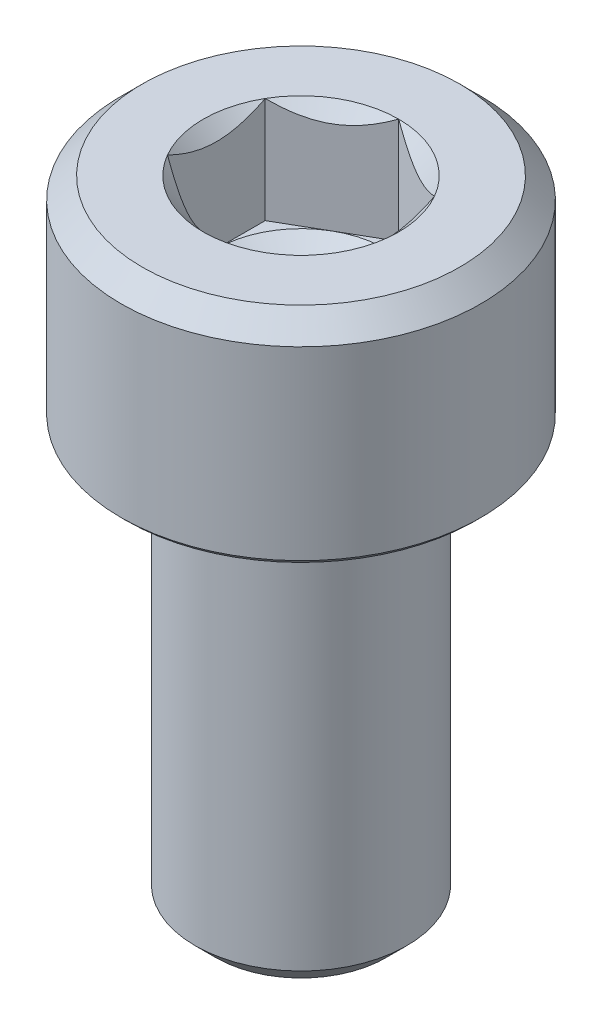
from build123d import *

# Parameters (mm, degrees)
CUT_EXTRUDE1_DEPTH = 2.5


with BuildPart() as part:
    # Sketch1 → Revolve1 (revolve)
    with BuildSketch(Plane.XY):
        Polygon((0, 1.345299462), (2, 2.5), (2, 4.690598923), (2.309401077, 5), (3.75, 5), (4.25, 4.5), (4.25, 0.125), (4.125, 0), (2.55, 0), (2.5, -0.6), (2.5, -9.5095), (2.0095, -10), (0, -10), align=None)
    revolve(axis=Axis((0, -10, 0), (0, 1, 0)))

    # Sketch2 → Cut-Extrude1 (cut)
    with BuildSketch(Plane(origin=(0, 5, 0), x_dir=(1, 0, 0), z_dir=(0, 1, 0))):
        Polygon((-2, -1.154700538), (0, -2.309401077), (2, -1.154700538), (2, 1.154700538), (0, 2.309401077), (-2, 1.154700538), align=None)
    extrude(amount=-CUT_EXTRUDE1_DEPTH, mode=Mode.SUBTRACT)


solid = part.part
